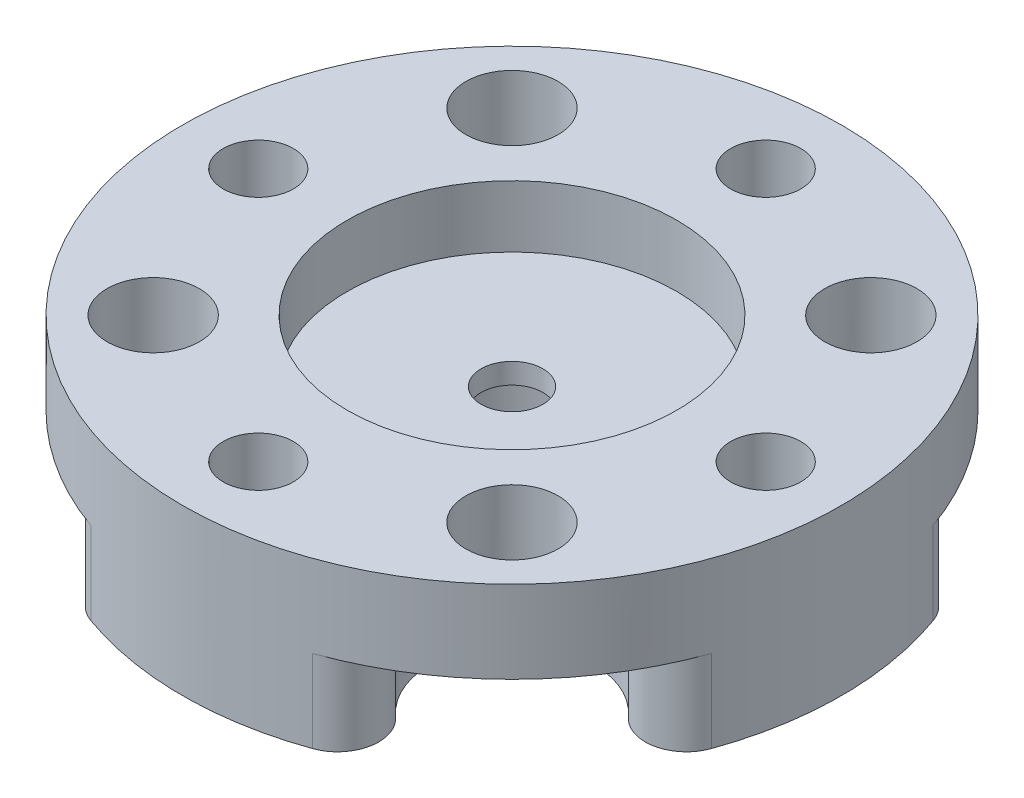
from build123d import *

# Parameters (mm, degrees)
SKETCH1_R             = 12.7
BOSS_EXTRUDE1_DEPTH   = 6.35
SKETCH2_R             = 6.35
CUT_EXTRUDE1_DEPTH    = 2.38125
SKETCH3_R             = 3.1115
CUT_EXTRUDE2_DEPTH    = 3.175
SKETCH4_R             = 1.190625
CUT_EXTRUDE3_DEPTH    = 4.96875
F_6_32_TAPPED_HOLE1_D = 2.7051
SKETCH7_R             = 1.778
CUT_EXTRUDE4_DEPTH    = 7.35
SKETCH8_R             = 3.175
CUT_EXTRUDE5_DEPTH    = 3.175
CIRPATTERN2_COUNT     = 4
FILLET1_R             = 1.5875


with BuildPart() as part:
    # Sketch1 → Boss-Extrude1 (new body)
    with BuildSketch(Plane(origin=(0, 0, 0), x_dir=(1, 0, 0), z_dir=(0, 1, 0))):
        Circle(SKETCH1_R)
    extrude(amount=BOSS_EXTRUDE1_DEPTH)

    # Sketch2 → Cut-Extrude1 (cut)
    with BuildSketch(Plane(origin=(0, 6.35, 0), x_dir=(1, 0, 0), z_dir=(0, 1, 0))):
        Circle(SKETCH2_R)
    extrude(amount=-CUT_EXTRUDE1_DEPTH, mode=Mode.SUBTRACT)

    # Sketch3 → Cut-Extrude2 (cut)
    with BuildSketch(Plane.XZ):
        Circle(SKETCH3_R)
    extrude(amount=-CUT_EXTRUDE2_DEPTH, mode=Mode.SUBTRACT)

    # Sketch4 → Cut-Extrude3 (cut, through all)
    with BuildSketch(Plane(origin=(0, 3.96875, 0), x_dir=(1, 0, 0), z_dir=(0, 1, 0))):
        Circle(SKETCH4_R)
    extrude(amount=-CUT_EXTRUDE3_DEPTH, mode=Mode.SUBTRACT)

    # #6-32 Tapped Hole1 (through all)
    with Locations(Plane(origin=(0, 6.35, 0), x_dir=(1, 0, 0), z_dir=(0, 1, 0))):
        with Locations((-9.779, 0)):
            f_6_32_tapped_hole1 = Hole(F_6_32_TAPPED_HOLE1_D / 2)

    # Sketch7 → Cut-Extrude4 (cut, through all)
    with BuildSketch(Plane(origin=(0, 6.35, 0), x_dir=(1, 0, 0), z_dir=(0, 1, 0))):
        with Locations((6.914797213, -6.914797213)):
            Circle(SKETCH7_R)
    cut_extrude4 = extrude(amount=-CUT_EXTRUDE4_DEPTH, mode=Mode.SUBTRACT)

    # Sketch8 → Cut-Extrude5 (cut)
    with BuildSketch(Plane.XZ):
        with Locations((6.914797213, 6.914797213)):
            Circle(SKETCH8_R)
    cut_extrude5 = extrude(amount=-CUT_EXTRUDE5_DEPTH, mode=Mode.SUBTRACT)

    # CirPattern2: #6-32 Tapped Hole1, Cut-Extrude4, Cut-Extrude5 ×4 about axis
    cirpattern2_axis = Axis((0, 0, 0), (0, 1, 0))
    for i in range(1, CIRPATTERN2_COUNT):
        add(f_6_32_tapped_hole1.rotate(cirpattern2_axis, i * 360 / CIRPATTERN2_COUNT), mode=Mode.SUBTRACT)
        add(cut_extrude4.rotate(cirpattern2_axis, i * 360 / CIRPATTERN2_COUNT), mode=Mode.SUBTRACT)
        add(cut_extrude5.rotate(cirpattern2_axis, i * 360 / CIRPATTERN2_COUNT), mode=Mode.SUBTRACT)

    # Fillet1
    fillet1_edges = [part.edges().sort_by_distance(p)[0] for p in [
        (7.923120818, 1.5875, 9.925429789),
        (9.925429789, 1.5875, 7.923120818),
        (9.925429789, 1.5875, -7.923120818),
        (7.923120818, 1.5875, -9.925429789),
        (-7.923120818, 1.5875, -9.925429789),
        (-9.925429789, 1.5875, -7.923120818),
        (-9.925429789, 1.5875, 7.923120818),
        (-7.923120818, 1.5875, 9.925429789),
    ]]
    fillet(fillet1_edges, radius=FILLET1_R)


solid = part.part
